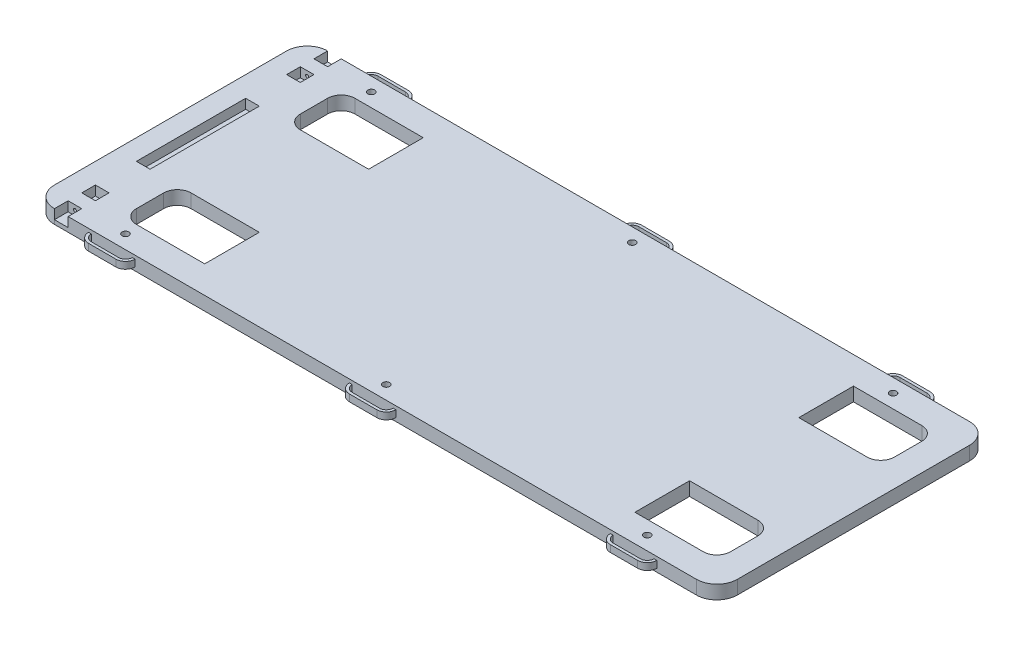
from build123d import *

# Parameters (mm, degrees)
BOSS_EXTRUDE1_DEPTH     = 12.7
BACKREST_BRACKET_SLOT_W = 12.7
BACKREST_BRACKET_SLOT_H = 8.89
CUT_EXTRUDE3_DEPTH      = 12.7
BACKREST_SCREW_HOLE_R   = 1.397
CUT_EXTRUDE4_DEPTH      = 6.35
CUT_EXTRUDE5_DEPTH      = 25.4
BOSS_EXTRUDE2_DEPTH     = 3.175
SKETCH37_W              = 12.7
SKETCH37_H              = 101.6
CUT_EXTRUDE7_DEPTH      = 8.89
SKETCH38_R              = 3.175
CUT_EXTRUDE8_DEPTH      = 12.7
SKETCH39_W              = 12.7
SKETCH39_H              = 12.7
CUT_EXTRUDE9_DEPTH      = 8.89
CUT_EXTRUDE10_START     = -12.7
SKETCH40_R              = 1.397
CUT_EXTRUDE10_DEPTH     = 6.35


with BuildPart() as part:
    # Main Body → Boss-Extrude1 (new body)
    with BuildSketch(Plane(origin=(0, 0, 0), x_dir=(1, 0, 0), z_dir=(0, 1, 0))):
        with BuildLine():
            Line((-317.5, -107.95), (-317.5, 107.95))
            ThreePointArc((-317.5, 107.95), (-311.920384182, 121.420384182), (-298.45, 127))
            Line((-298.45, 127), (298.45, 127))
            ThreePointArc((298.45, 127), (311.920384182, 121.420384182), (317.5, 107.95))
            Line((317.5, 107.95), (317.5, -107.95))
            ThreePointArc((317.5, -107.95), (311.920384182, -121.420384182), (298.45, -127))
            Line((298.45, -127), (-298.45, -127))
            ThreePointArc((-298.45, -127), (-311.920384182, -121.420384182), (-317.5, -107.95))
        make_face()
    extrude(amount=BOSS_EXTRUDE1_DEPTH)

    # Backrest Bracket Slot → Cut-Extrude3 (cut)
    with BuildSketch(Plane.XY.offset(127)):
        with Locations((-292.1, 8.255)):
            Rectangle(BACKREST_BRACKET_SLOT_W, BACKREST_BRACKET_SLOT_H)
    cut_extrude3 = extrude(amount=-CUT_EXTRUDE3_DEPTH, mode=Mode.SUBTRACT)

    # Backrest Screw Hole → Cut-Extrude4 (cut)
    with BuildSketch(Plane.XY.offset(114.3)):
        with Locations((-292.1, 8.255)):
            Circle(BACKREST_SCREW_HOLE_R)
    cut_extrude4 = extrude(amount=-CUT_EXTRUDE4_DEPTH, mode=Mode.SUBTRACT)

    # Mirror1: Cut-Extrude3, Cut-Extrude4 across plane
    add(cut_extrude3.mirror(Plane.XY), mode=Mode.SUBTRACT)
    add(cut_extrude4.mirror(Plane.XY), mode=Mode.SUBTRACT)

    # Couch Foot Slits → Cut-Extrude5 (cut)
    with BuildSketch(Plane(origin=(0, 12.7, 0), x_dir=(1, 0, 0), z_dir=(0, 1, 0))):
        with BuildLine():
            Line((-247.65, 101.6), (-184.15, 101.6))
            Line((-184.15, 101.6), (-184.15, 50.8))
            Line((-184.15, 50.8), (-247.65, 50.8))
            ThreePointArc((-247.65, 50.8), (-256.630256121, 54.519743879), (-260.35, 63.5))
            Line((-260.35, 63.5), (-260.35, 88.9))
            ThreePointArc((-260.35, 88.9), (-256.630256121, 97.880256121), (-247.65, 101.6))
        make_face()
        with BuildLine():
            Line((292.1, 88.9), (292.1, 63.5))
            ThreePointArc((292.1, 63.5), (288.380256121, 54.519743879), (279.4, 50.8))
            Line((279.4, 50.8), (215.9, 50.8))
            Line((215.9, 50.8), (215.9, 101.6))
            Line((215.9, 101.6), (279.4, 101.6))
            ThreePointArc((279.4, 101.6), (288.380256121, 97.880256121), (292.1, 88.9))
        make_face()
        with BuildLine():
            Line((-247.65, -50.8), (-184.15, -50.8))
            Line((-184.15, -50.8), (-184.15, -101.6))
            Line((-184.15, -101.6), (-247.65, -101.6))
            ThreePointArc((-247.65, -101.6), (-256.630256121, -97.880256121), (-260.35, -88.9))
            Line((-260.35, -88.9), (-260.35, -63.5))
            ThreePointArc((-260.35, -63.5), (-256.630256121, -54.519743879), (-247.65, -50.8))
        make_face()
        with BuildLine():
            Line((292.1, -63.5), (292.1, -88.9))
            ThreePointArc((292.1, -88.9), (288.380256121, -97.880256121), (279.4, -101.6))
            Line((279.4, -101.6), (215.9, -101.6))
            Line((215.9, -101.6), (215.9, -50.8))
            Line((215.9, -50.8), (279.4, -50.8))
            ThreePointArc((279.4, -50.8), (288.380256121, -54.519743879), (292.1, -63.5))
        make_face()
    extrude(amount=-CUT_EXTRUDE5_DEPTH, mode=Mode.SUBTRACT)

    # Sketch24 → Boss-Extrude2 (add, symmetric)
    with BuildSketch(Plane(origin=(0, 6.35, 0), x_dir=(1, 0, 0), z_dir=(0, 1, 0))):
        with BuildLine():
            Line((-15.24, -133.35), (10.16, -133.35))
            ThreePointArc((10.16, -133.35), (14.650128061, -131.490128061), (16.51, -127))
            Line((16.51, -127), (19.05, -127))
            ThreePointArc((19.05, -127), (16.446179285, -133.286179285), (10.16, -135.89))
            Line((10.16, -135.89), (-15.24, -135.89))
            ThreePointArc((-15.24, -135.89), (-21.526179285, -133.286179285), (-24.13, -127))
            Line((-24.13, -127), (-21.59, -127))
            ThreePointArc((-21.59, -127), (-19.730128061, -131.490128061), (-15.24, -133.35))
        make_face()
        with BuildLine():
            Line((-257.81, -133.35), (-232.41, -133.35))
            ThreePointArc((-232.41, -133.35), (-227.919871939, -131.490128061), (-226.06, -127))
            Line((-226.06, -127), (-223.52, -127))
            ThreePointArc((-223.52, -127), (-226.123820715, -133.286179285), (-232.41, -135.89))
            Line((-232.41, -135.89), (-257.81, -135.89))
            ThreePointArc((-257.81, -135.89), (-264.096179285, -133.286179285), (-266.7, -127))
            Line((-266.7, -127), (-264.16, -127))
            ThreePointArc((-264.16, -127), (-262.300128061, -131.490128061), (-257.81, -133.35))
        make_face()
        with BuildLine():
            Line((227.33, -133.35), (252.73, -133.35))
            ThreePointArc((252.73, -133.35), (257.220128061, -131.490128061), (259.08, -127))
            Line((259.08, -127), (261.62, -127))
            ThreePointArc((261.62, -127), (259.016179285, -133.286179285), (252.73, -135.89))
            Line((252.73, -135.89), (227.33, -135.89))
            ThreePointArc((227.33, -135.89), (221.043820715, -133.286179285), (218.44, -127))
            Line((218.44, -127), (220.98, -127))
            ThreePointArc((220.98, -127), (222.839871939, -131.490128061), (227.33, -133.35))
        make_face()
    boss_extrude2 = extrude(amount=BOSS_EXTRUDE2_DEPTH, both=True)

    # Mirror2: Boss-Extrude2 across plane
    add(boss_extrude2.mirror(Plane.XY))

    # Sketch37 → Cut-Extrude7 (cut)
    with BuildSketch(Plane(origin=(0, 12.7, 0), x_dir=(1, 0, 0), z_dir=(0, 1, 0))):
        with Locations((-292.1, 0)):
            Rectangle(SKETCH37_W, SKETCH37_H)
    extrude(amount=-CUT_EXTRUDE7_DEPTH, mode=Mode.SUBTRACT)

    # Sketch38 → Cut-Extrude8 (cut)
    with BuildSketch(Plane(origin=(0, 12.7, 0), x_dir=(1, 0, 0), z_dir=(0, 1, 0))):
        with Locations((-245.11, -114.3)):
            Circle(SKETCH38_R)
        with Locations((-2.54, -114.3)):
            Circle(SKETCH38_R)
        with Locations((240.03, -114.3)):
            Circle(SKETCH38_R)
    cut_extrude8 = extrude(amount=-CUT_EXTRUDE8_DEPTH, mode=Mode.SUBTRACT)

    # Mirror3: Cut-Extrude8 across plane
    add(cut_extrude8.mirror(Plane.XY), mode=Mode.SUBTRACT)

    # Sketch39 → Cut-Extrude9 (cut)
    with BuildSketch(Plane(origin=(0, 12.7, 0), x_dir=(1, 0, 0), z_dir=(0, 1, 0))):
        with Locations((-292.1, -95.25)):
            Rectangle(SKETCH39_W, SKETCH39_H)
    cut_extrude9 = extrude(amount=-CUT_EXTRUDE9_DEPTH, mode=Mode.SUBTRACT)

    # Sketch40 → Cut-Extrude10 (cut)
    with BuildSketch(Plane.XY.offset(114.3).offset(CUT_EXTRUDE10_START)):
        with Locations((-292.1, 8.255)):
            Circle(SKETCH40_R)
    cut_extrude10 = extrude(amount=CUT_EXTRUDE10_DEPTH, mode=Mode.SUBTRACT)

    # Mirror5: Cut-Extrude9, Cut-Extrude10 across plane
    add(cut_extrude9.mirror(Plane.XY), mode=Mode.SUBTRACT)
    add(cut_extrude10.mirror(Plane.XY), mode=Mode.SUBTRACT)


solid = part.part
